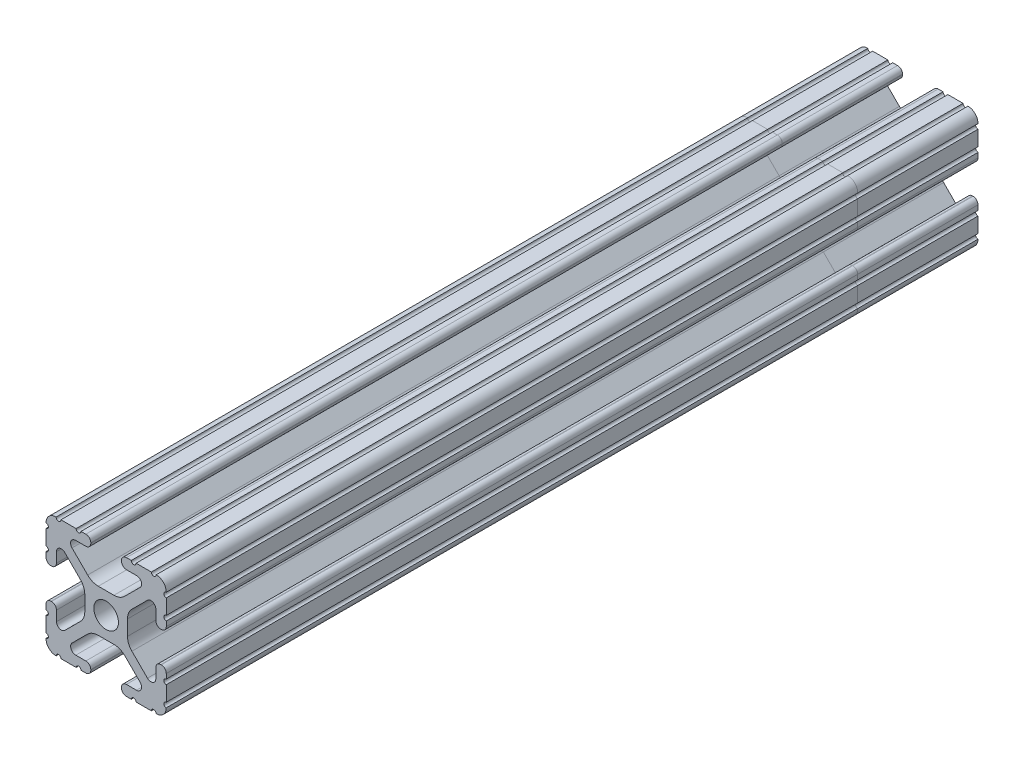
from build123d import *

# Parameters (mm, degrees)
SKETCH1_R           = 2.6035
BOSS_EXTRUDE1_DEPTH = 85.725


with BuildPart() as part:
    # Sketch1 → Boss-Extrude1 (new body, symmetric)
    with BuildSketch(Plane.XY):
        with BuildLine():
            Line((-7.179650497, -8.645192506), (-3.952270251, -5.423690499))
            ThreePointArc((-3.952270251, -5.423690499), (-2.922936451, -4.736929036), (-1.709253557, -4.4958))
            Line((-1.709253557, -4.4958), (1.709253557, -4.4958))
            ThreePointArc((1.709253557, -4.4958), (2.922936451, -4.736929036), (3.952270251, -5.423690499))
            Line((3.952270251, -5.423690499), (7.179650497, -8.645192506))
            ThreePointArc((7.179650497, -8.645192506), (7.41473083, -9.822813117), (6.416408329, -10.4902))
            Line((6.416408329, -10.4902), (4.287512407, -10.4902))
            ThreePointArc((4.287512407, -10.4902), (3.54574862, -10.79744862), (3.2385, -11.539212407))
            Line((3.2385, -11.539212407), (3.2385, -11.650987593))
            ThreePointArc((3.2385, -11.650987593), (3.54574862, -12.39275138), (4.287512407, -12.7))
            Line((4.287512407, -12.7), (5.317126718, -12.7))
            ThreePointArc((5.317126718, -12.7), (5.825126718, -12.192), (6.333126718, -12.7))
            Line((6.333126718, -12.7), (9.550443118, -12.7))
            ThreePointArc((9.550443118, -12.7), (10.058366869, -12.192000006), (10.566443095, -12.699847501))
            ThreePointArc((10.566443095, -12.699847501), (12.082537762, -12.08250727), (12.699846982, -10.566399977))
            ThreePointArc((12.699846982, -10.566399977), (12.192000006, -10.058323491), (12.7, -9.5504))
            Line((12.7, -9.5504), (12.7, -6.3330836))
            ThreePointArc((12.7, -6.3330836), (12.192, -5.8250836), (12.7, -5.3170836))
            Line((12.7, -5.3170836), (12.7, -4.287469289))
            ThreePointArc((12.7, -4.287469289), (12.39275138, -3.545705502), (11.650987593, -3.238456882))
            Line((11.650987593, -3.238456882), (11.539212407, -3.238456882))
            ThreePointArc((11.539212407, -3.238456882), (10.79744862, -3.545705502), (10.4902, -4.287469289))
            Line((10.4902, -4.287469289), (10.4902, -6.402089023))
            ThreePointArc((10.4902, -6.402089023), (9.856505071, -7.351067942), (8.737131347, -7.129408934))
            Line((8.737131347, -7.129408934), (5.441005833, -3.840816462))
            ThreePointArc((5.441005833, -3.840816462), (4.750877967, -2.809883091), (4.5085, -1.593185507))
            Line((4.5085, -1.593185507), (4.5085, 1.593185507))
            ThreePointArc((4.5085, 1.593185507), (4.750877967, 2.809883091), (5.441005833, 3.840816462))
            Line((5.441005833, 3.840816462), (8.737131347, 7.129408934))
            ThreePointArc((8.737131347, 7.129408934), (9.856505071, 7.351067942), (10.4902, 6.402089023))
            Line((10.4902, 6.402089023), (10.4902, 4.287469289))
            ThreePointArc((10.4902, 4.287469289), (10.79744862, 3.545705502), (11.539212407, 3.238456882))
            Line((11.539212407, 3.238456882), (11.650987593, 3.238456882))
            ThreePointArc((11.650987593, 3.238456882), (12.39275138, 3.545705502), (12.7, 4.287469289))
            Line((12.7, 4.287469289), (12.7, 5.3170836))
            ThreePointArc((12.7, 5.3170836), (12.192, 5.8250836), (12.7, 6.3330836))
            Line((12.7, 6.3330836), (12.7, 9.5504))
            ThreePointArc((12.7, 9.5504), (12.192000006, 10.058323491), (12.699846982, 10.566399977))
            ThreePointArc((12.699846982, 10.566399977), (12.082537762, 12.08250727), (10.566443095, 12.699847501))
            ThreePointArc((10.566443095, 12.699847501), (10.058366869, 12.192000006), (9.550443118, 12.7))
            Line((9.550443118, 12.7), (6.333126718, 12.7))
            ThreePointArc((6.333126718, 12.7), (5.825126718, 12.192), (5.317126718, 12.7))
            Line((5.317126718, 12.7), (4.287512407, 12.7))
            ThreePointArc((4.287512407, 12.7), (3.54574862, 12.39275138), (3.2385, 11.650987593))
            Line((3.2385, 11.650987593), (3.2385, 11.539212407))
            ThreePointArc((3.2385, 11.539212407), (3.54574862, 10.79744862), (4.287512407, 10.4902))
            Line((4.287512407, 10.4902), (6.476788598, 10.4902))
            ThreePointArc((6.476788598, 10.4902), (7.432222385, 9.85140422), (7.207036008, 8.724370562))
            Line((7.207036008, 8.724370562), (3.898272566, 5.423169045))
            ThreePointArc((3.898272566, 5.423169045), (2.869120213, 4.736787962), (1.655778399, 4.4958))
            Line((1.655778399, 4.4958), (-1.655778399, 4.4958))
            ThreePointArc((-1.655778399, 4.4958), (-2.869120213, 4.736787962), (-3.898272566, 5.423169045))
            Line((-3.898272566, 5.423169045), (-7.207036008, 8.724370562))
            ThreePointArc((-7.207036008, 8.724370562), (-7.432222385, 9.85140422), (-6.476788598, 10.4902))
            Line((-6.476788598, 10.4902), (-4.287512407, 10.4902))
            ThreePointArc((-4.287512407, 10.4902), (-3.54574862, 10.79744862), (-3.2385, 11.539212407))
            Line((-3.2385, 11.539212407), (-3.2385, 11.650987593))
            ThreePointArc((-3.2385, 11.650987593), (-3.54574862, 12.39275138), (-4.287512407, 12.7))
            Line((-4.287512407, 12.7), (-5.317126718, 12.7))
            ThreePointArc((-5.317126718, 12.7), (-5.825126718, 12.192), (-6.333126718, 12.7))
            Line((-6.333126718, 12.7), (-9.550443118, 12.7))
            ThreePointArc((-9.550443118, 12.7), (-10.058366869, 12.192000006), (-10.566443095, 12.699847501))
            ThreePointArc((-10.566443095, 12.699847501), (-12.082537762, 12.08250727), (-12.699846982, 10.566399977))
            ThreePointArc((-12.699846982, 10.566399977), (-12.192000006, 10.058323491), (-12.7, 9.5504))
            Line((-12.7, 9.5504), (-12.7, 6.3330836))
            ThreePointArc((-12.7, 6.3330836), (-12.192, 5.8250836), (-12.7, 5.3170836))
            Line((-12.7, 5.3170836), (-12.7, 4.287469289))
            ThreePointArc((-12.7, 4.287469289), (-12.39275138, 3.545705502), (-11.650987593, 3.238456882))
            Line((-11.650987593, 3.238456882), (-11.539212407, 3.238456882))
            ThreePointArc((-11.539212407, 3.238456882), (-10.79744862, 3.545705502), (-10.4902, 4.287469289))
            Line((-10.4902, 4.287469289), (-10.4902, 6.402089023))
            ThreePointArc((-10.4902, 6.402089023), (-9.856505071, 7.351067942), (-8.737131347, 7.129408934))
            Line((-8.737131347, 7.129408934), (-5.441005833, 3.840816462))
            ThreePointArc((-5.441005833, 3.840816462), (-4.750877967, 2.809883091), (-4.5085, 1.593185507))
            Line((-4.5085, 1.593185507), (-4.5085, -1.593185507))
            ThreePointArc((-4.5085, -1.593185507), (-4.750877967, -2.809883091), (-5.441005833, -3.840816462))
            Line((-5.441005833, -3.840816462), (-8.737131347, -7.129408934))
            ThreePointArc((-8.737131347, -7.129408934), (-9.856505071, -7.351067942), (-10.4902, -6.402089023))
            Line((-10.4902, -6.402089023), (-10.4902, -4.287469289))
            ThreePointArc((-10.4902, -4.287469289), (-10.79744862, -3.545705502), (-11.539212407, -3.238456882))
            Line((-11.539212407, -3.238456882), (-11.650987593, -3.238456882))
            ThreePointArc((-11.650987593, -3.238456882), (-12.39275138, -3.545705502), (-12.7, -4.287469289))
            Line((-12.7, -4.287469289), (-12.7, -5.3170836))
            ThreePointArc((-12.7, -5.3170836), (-12.192, -5.8250836), (-12.7, -6.3330836))
            Line((-12.7, -6.3330836), (-12.7, -9.5504))
            ThreePointArc((-12.7, -9.5504), (-12.192000006, -10.058323491), (-12.699846982, -10.566399977))
            ThreePointArc((-12.699846982, -10.566399977), (-12.082537762, -12.08250727), (-10.566443095, -12.699847501))
            ThreePointArc((-10.566443095, -12.699847501), (-10.058366869, -12.192000006), (-9.550443118, -12.7))
            Line((-9.550443118, -12.7), (-6.333126718, -12.7))
            ThreePointArc((-6.333126718, -12.7), (-5.825126718, -12.192), (-5.317126718, -12.7))
            Line((-5.317126718, -12.7), (-4.287512407, -12.7))
            ThreePointArc((-4.287512407, -12.7), (-3.54574862, -12.39275138), (-3.2385, -11.650987593))
            Line((-3.2385, -11.650987593), (-3.2385, -11.539212407))
            ThreePointArc((-3.2385, -11.539212407), (-3.54574862, -10.79744862), (-4.287512407, -10.4902))
            Line((-4.287512407, -10.4902), (-6.416408329, -10.4902))
            ThreePointArc((-6.416408329, -10.4902), (-7.41473083, -9.822813117), (-7.179650497, -8.645192506))
        make_face()
        Circle(SKETCH1_R, mode=Mode.SUBTRACT)
    extrude(amount=BOSS_EXTRUDE1_DEPTH, both=True)


with BuildPart() as body_2:
    # Split1: the piece on the far side of the plane
    add(part.part)
    split(bisect_by=Plane(origin=(0, 0, -60.325), x_dir=(-1, 0, 0), z_dir=(0, 0, -1)), keep=Keep.BOTTOM)


with BuildPart() as part_1:
    add(part.part)

    # Split1
    split(bisect_by=Plane(origin=(0, 0, -60.325), x_dir=(-1, 0, 0), z_dir=(0, 0, -1)), keep=Keep.TOP)


solid = Compound([body_2.part, part_1.part])
